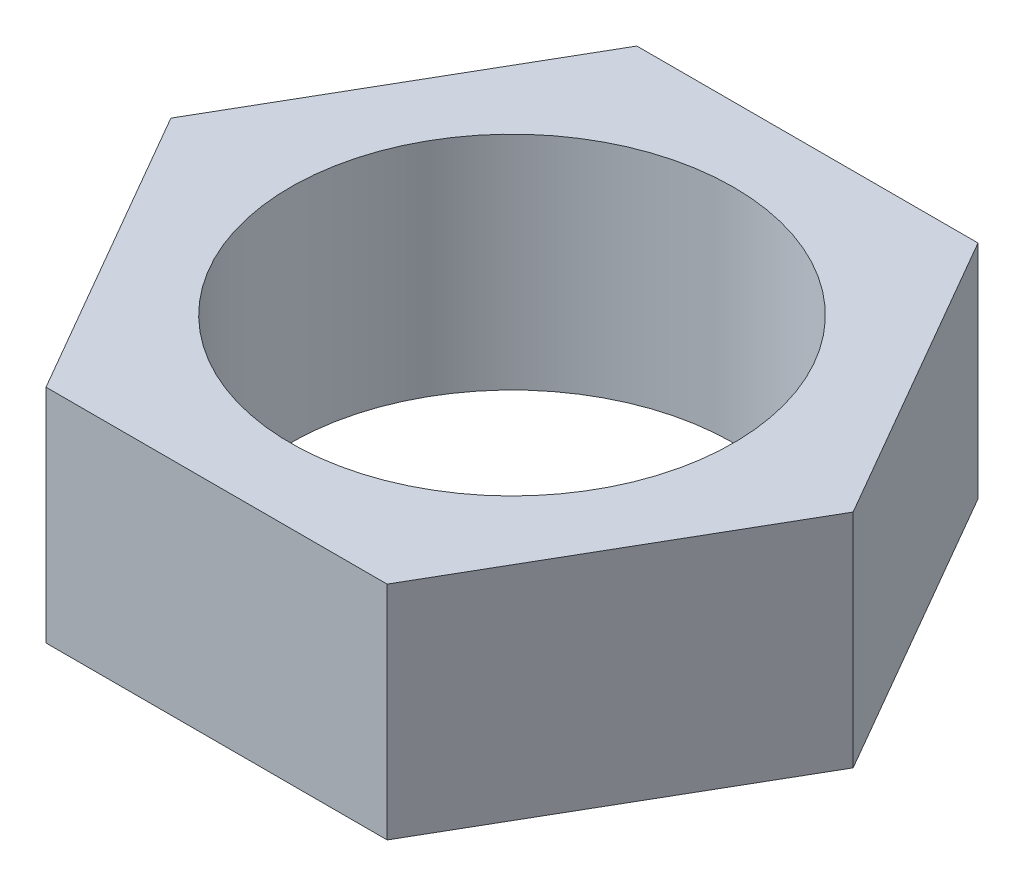
from build123d import *

# Parameters (mm, degrees)
EXTRUDE_1_DEPTH     = 3
SKETCH_2_R          = 3
CUT_EXTRUDE_1_DEPTH = 3


with BuildPart() as part:
    # 草圖1 → 填料-伸長1 (new body)
    with BuildSketch(Plane(origin=(0, 0, 0), x_dir=(1, 0, 0), z_dir=(0, 1, 0))):
        Polygon((4.618802154, 0), (2.309401077, 4), (-2.309401077, 4), (-4.618802154, 0), (-2.309401077, -4), (2.309401077, -4), align=None)
    extrude(amount=EXTRUDE_1_DEPTH)

    # 草圖2 → 除料-伸長1 (cut)
    with BuildSketch(Plane.XZ):
        Circle(SKETCH_2_R)
    extrude(amount=-CUT_EXTRUDE_1_DEPTH, mode=Mode.SUBTRACT)


solid = part.part
